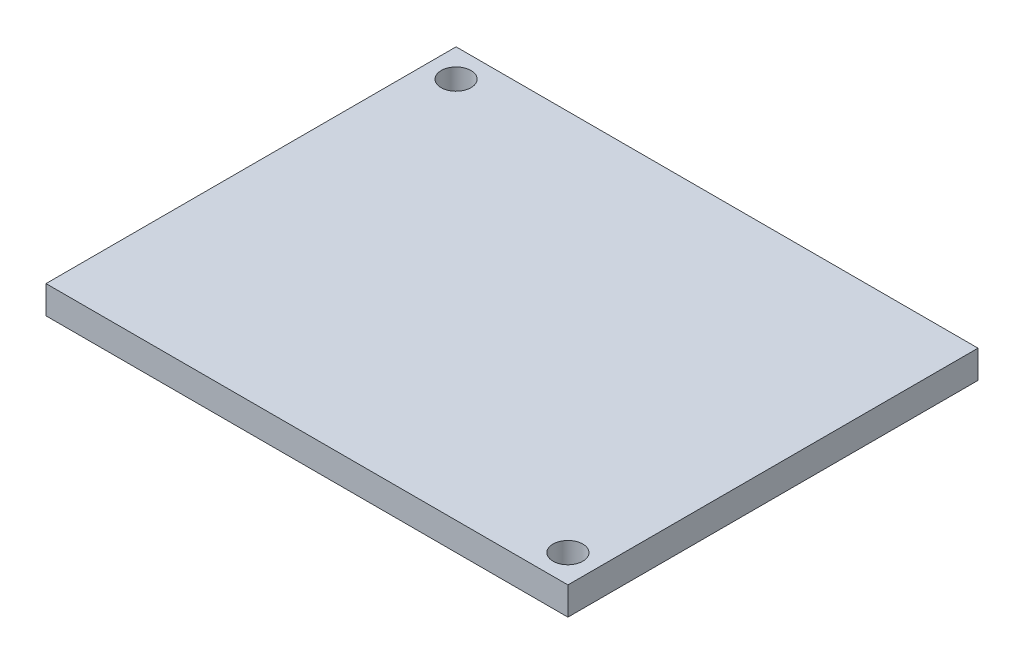
from build123d import *

# Parameters (mm, degrees)
SKETCH1_W           = 56
SKETCH1_H           = 44
BOSS_EXTRUDE1_DEPTH = 3
SKETCH2_R           = 1.6
CUT_EXTRUDE1_DEPTH  = 3
SKETCH4_R           = 1.6
CUT_EXTRUDE2_DEPTH  = 3


with BuildPart() as part:
    # Sketch1 → Boss-Extrude1 (new body)
    with BuildSketch(Plane(origin=(0, 0, 0), x_dir=(1, 0, 0), z_dir=(0, 1, 0))):
        with Locations((-507.449567723, 334.295389049)):
            Rectangle(SKETCH1_W, SKETCH1_H)
    extrude(amount=BOSS_EXTRUDE1_DEPTH)

    # Sketch2 → Cut-Extrude1 (cut)
    with BuildSketch(Plane(origin=(0, 3, 0), x_dir=(1, 0, 0), z_dir=(0, 1, 0))):
        with Locations((-532.449567723, 353.295389049)):
            Circle(SKETCH2_R)
    extrude(amount=-CUT_EXTRUDE1_DEPTH, mode=Mode.SUBTRACT)

    # Sketch4 → Cut-Extrude2 (cut)
    with BuildSketch(Plane(origin=(0, 3, 0), x_dir=(1, 0, 0), z_dir=(0, 1, 0))):
        with Locations((-482.449567723, 315.295389049)):
            Circle(SKETCH4_R)
    extrude(amount=-CUT_EXTRUDE2_DEPTH, mode=Mode.SUBTRACT)


solid = part.part
